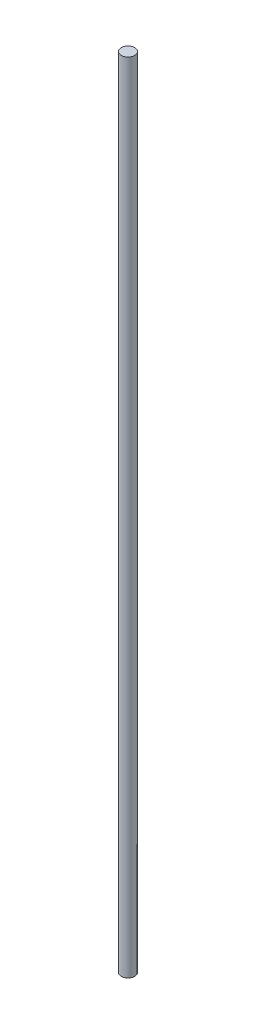
from build123d import *

# Parameters (mm, degrees)
SKETCH1_R           = 4.5
BOSS_EXTRUDE1_DEPTH = 533


with BuildPart() as part:
    # Sketch1 → Boss-Extrude1 (new body)
    with BuildSketch(Plane(origin=(0, 0, 0), x_dir=(1, 0, 0), z_dir=(0, 1, 0))):
        Circle(SKETCH1_R)
    extrude(amount=BOSS_EXTRUDE1_DEPTH)


solid = part.part
